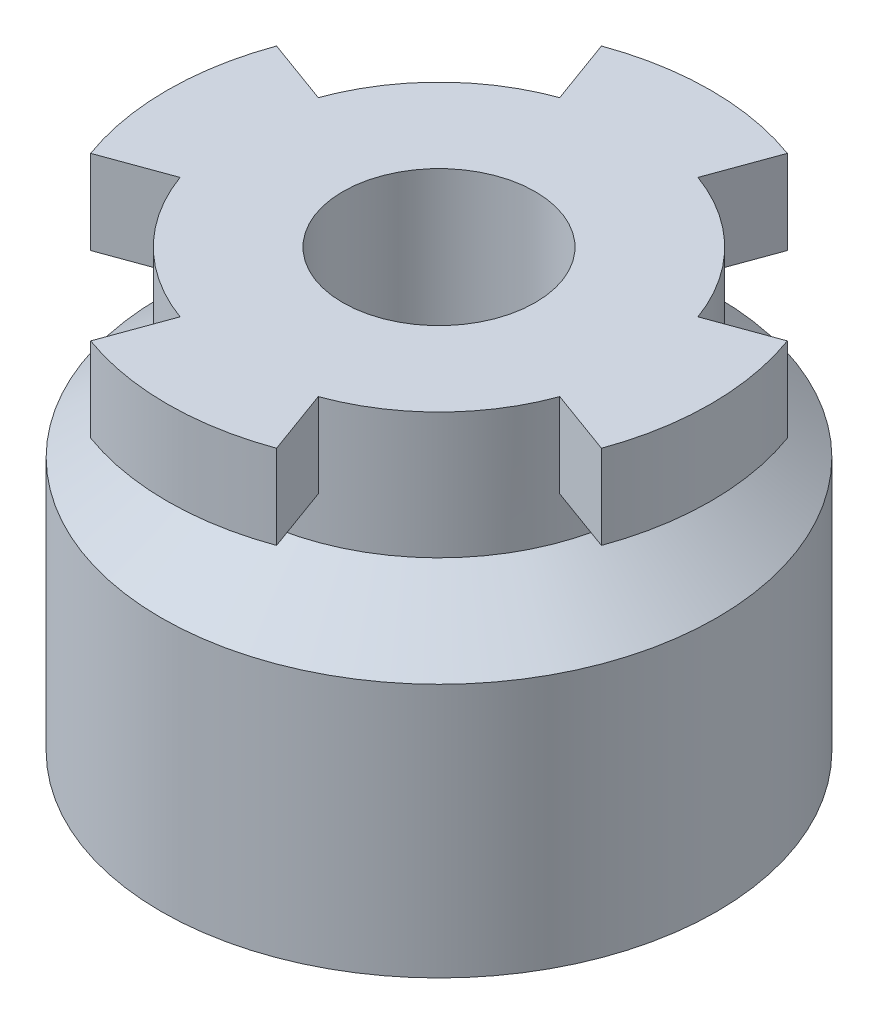
from build123d import *

# Parameters (mm, degrees)
DODANIE_WYCI_GNI_CIE1_DEPTH = 7


with BuildPart() as part:
    # Szkic1 → Obrót1 (revolve)
    with BuildSketch(Plane.XY):
        Polygon((0, 0), (-23.1, 0), (-23.1, 21.15), (-16.8, 25.8), (-16.8, 36.3), (-8, 36.3), (-8, 22.3), (0, 22.3), align=None)
    revolve(axis=Axis((0, 22.3, 0), (0, -1, 0)))

    # Szkic2 → Dodanie-wyciągnięcie1 (add)
    with BuildSketch(Plane(origin=(0, 36.3, 0), x_dir=(1, 0, 0), z_dir=(0, 1, 0))):
        with BuildLine():
            Line((-7.729655239, 21.23705323), (-5.745938408, 15.786836029))
            ThreePointArc((-5.745938408, 15.786836029), (0, 16.8), (5.745938408, 15.786836029))
            Line((5.745938408, 15.786836029), (7.729655239, 21.23705323))
            ThreePointArc((7.729655239, 21.23705323), (0, 22.6), (-7.729655239, 21.23705323))
        make_face()
        with BuildLine():
            ThreePointArc((15.786836029, 5.745938408), (16.8, 0), (15.786836029, -5.745938408))
            Line((15.786836029, -5.745938408), (21.23705323, -7.729655239))
            ThreePointArc((21.23705323, -7.729655239), (22.6, 0), (21.23705323, 7.729655239))
            Line((21.23705323, 7.729655239), (15.786836029, 5.745938408))
        make_face()
        with BuildLine():
            ThreePointArc((5.745938408, -15.786836029), (0, -16.8), (-5.745938408, -15.786836029))
            Line((-5.745938408, -15.786836029), (-7.729655239, -21.23705323))
            ThreePointArc((-7.729655239, -21.23705323), (0, -22.6), (7.729655239, -21.23705323))
            Line((7.729655239, -21.23705323), (5.745938408, -15.786836029))
        make_face()
        with BuildLine():
            ThreePointArc((-15.786836029, -5.745938408), (-16.8, 0), (-15.786836029, 5.745938408))
            Line((-15.786836029, 5.745938408), (-21.23705323, 7.729655239))
            ThreePointArc((-21.23705323, 7.729655239), (-22.6, 0), (-21.23705323, -7.729655239))
            Line((-21.23705323, -7.729655239), (-15.786836029, -5.745938408))
        make_face()
    extrude(amount=-DODANIE_WYCI_GNI_CIE1_DEPTH)


solid = part.part
